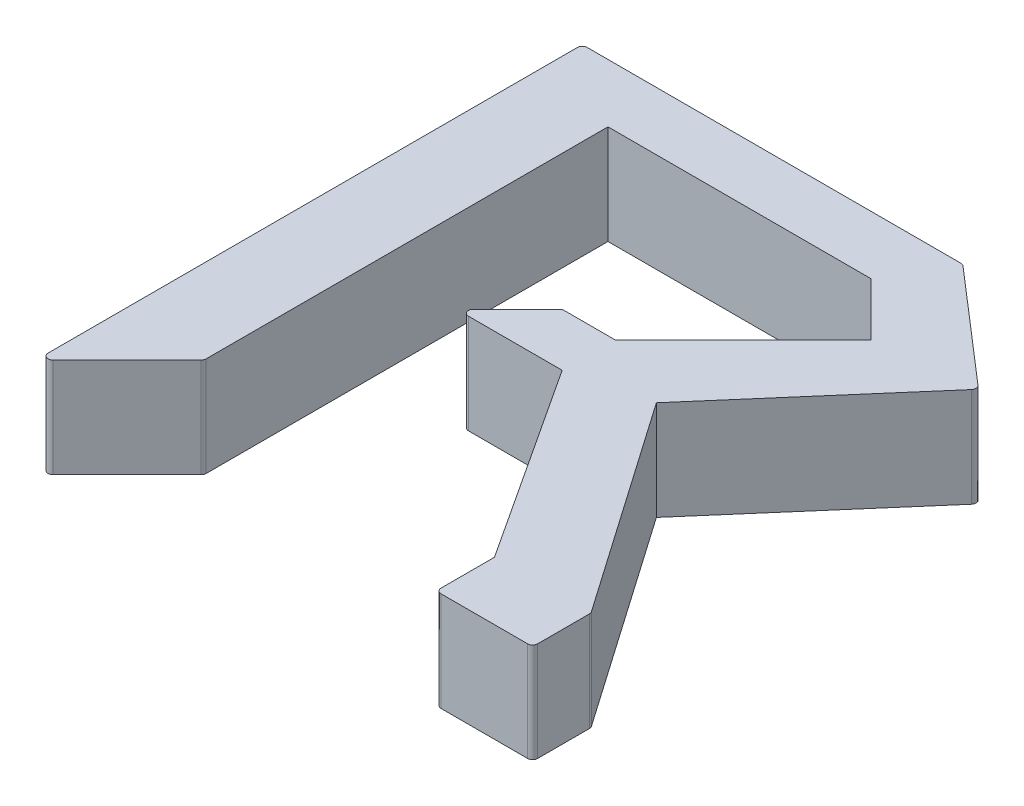
from build123d import *

# Parameters (mm, degrees)
BOSS_EXTRUDE1_DEPTH = 10
FILLET1_R           = 0.5


with BuildPart() as part:
    # Sketch2 → Boss-Extrude1 (new body)
    with BuildSketch(Plane(origin=(0, 0, 0), x_dir=(1, 0, 0), z_dir=(0, 1, 0))):
        Polygon((0, 0), (8.461538462, 8.461538462), (8.461538462, 49.123931624), (34.959843123, 49.123931624), (40.27906686, 43.804707886), (27.382478632, 30.908119658), (22.063254895, 30.908119658), (16.744031157, 25.58889592), (27.382478632, 25.58889592), (40.27906686, 5.876068376), (40.27906686, 0), (50, 0), (50, 5.876068376), (34.959843123, 27.5), (50, 44.893162393), (38.311965812, 55), (0, 55), align=None)
    extrude(amount=BOSS_EXTRUDE1_DEPTH)

    # Fillet1
    fillet1_edges = [part.edges().sort_by_distance(p)[0] for p in [
        (0, 5, -55),
        (38.311965812, 5, -55),
        (50, 5, -44.893162393),
        (50, 5, -5.876068376),
        (50, 5, 0),
        (40.27906686, 5, 0),
        (16.744031157, 5, -25.58889592),
        (22.063254895, 5, -30.908119658),
        (8.461538462, 5, -8.461538462),
        (0, 5, 0),
    ]]
    fillet(fillet1_edges, radius=FILLET1_R)


solid = part.part
